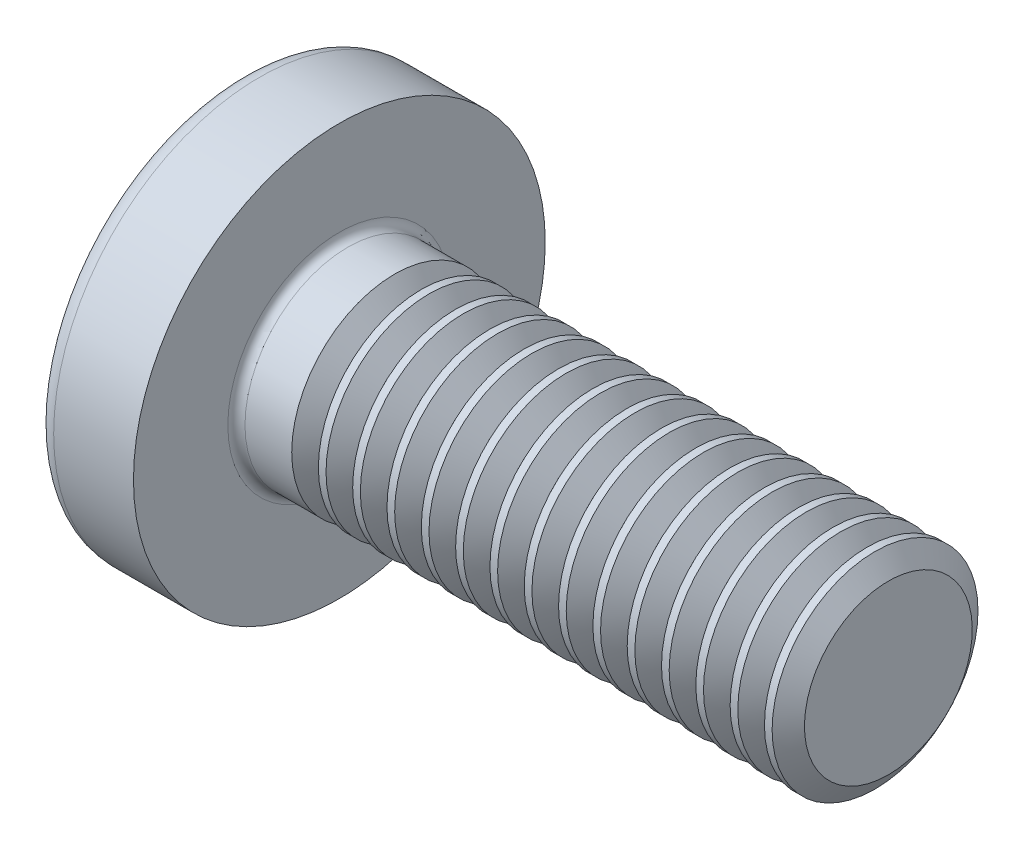
from build123d import *

# Parameters (mm, degrees)
FILLET1_R       = 0.25
SKETCH3_W       = 1.42
SKETCH3_H       = 6.7
SKETCH4_W       = 1.42
SKETCH4_H       = 3.249815392
RECPAT_COUNT    = 2
RECPAT_ANGLE    = 90
THDSCHPAT_COUNT = 15
THDSCHPAT_PITCH = 1


with BuildPart() as part:
    # BodySke → Base-Revolve (revolve)
    with BuildSketch(Plane.XY):
        with BuildLine():
            Line((4.6, 3), (4.6, 6))
            Line((4.6, 6), (2.274716834, 6))
            ThreePointArc((2.274716834, 6), (2.026424569, 5.939532013), (1.833738725, 5.77167019))
            ThreePointArc((1.833738725, 5.77167019), (0.469454036, 3.027985077), (0, 0))
            Line((0, 0), (20.6, 0))
            Line((20.6, 0), (20.6, 3))
            Line((20.6, 3), (4.6, 3))
        make_face()
    revolve(axis=Axis((-25.4, 0, 0), (1, 0, 0)))

    # Fillet1
    fillet1_edges = [part.edges().sort_by_distance(p)[0] for p in [
        (4.6, -3, 0),
    ]]
    fillet(fillet1_edges, radius=FILLET1_R)

    # Sketch3 → Recess section 0
    with BuildSketch(Plane(origin=(0, 0, 0), x_dir=(0, 0, -1), z_dir=(1, 0, 0))):
        Rectangle(SKETCH3_W, SKETCH3_H)
    # Sketch4 → Recess section 1
    with BuildSketch(Plane(origin=(3.46, 0, 0), x_dir=(0, 0, -1), z_dir=(1, 0, 0))):
        Rectangle(SKETCH4_W, SKETCH4_H)
    recess = loft(mode=Mode.SUBTRACT)

    # RecPat: Recess ×2 about axis
    recpat_axis = Axis((0, 0, 0), (1, 0, 0))
    for i in range(1, RECPAT_COUNT):
        add(recess.rotate(recpat_axis, i * RECPAT_ANGLE / (RECPAT_COUNT - 1)), mode=Mode.SUBTRACT)

    # RecCorSke → RecessCore (revolve, cut)
    with BuildSketch(Plane.XY):
        Polygon((0, 0), (0, 1.522446769), (3.46, 1.2805), (3.876059671, 0), align=None)
    revolve(axis=Axis((-3.175, 0, 0), (1, 0, 0)), mode=Mode.SUBTRACT)

    # ThdSchSke → ThreadSchematic (revolve, cut)
    with BuildSketch(Plane.XY):
        Polygon((6.6, -2.4455), (6.21173492, -3), (6.21173492, -3.75), (6.98826508, -3.75), (6.98826508, -3), align=None)
    threadschematic = revolve(axis=Axis((-3.175, 0, 0), (1, 0, 0)), mode=Mode.SUBTRACT)

    # ThdSchPat: ThreadSchematic ×15
    with Locations(*[(i * THDSCHPAT_PITCH, 0, 0) for i in range(1, THDSCHPAT_COUNT)]):
        add(threadschematic, mode=Mode.SUBTRACT)


solid = part.part
